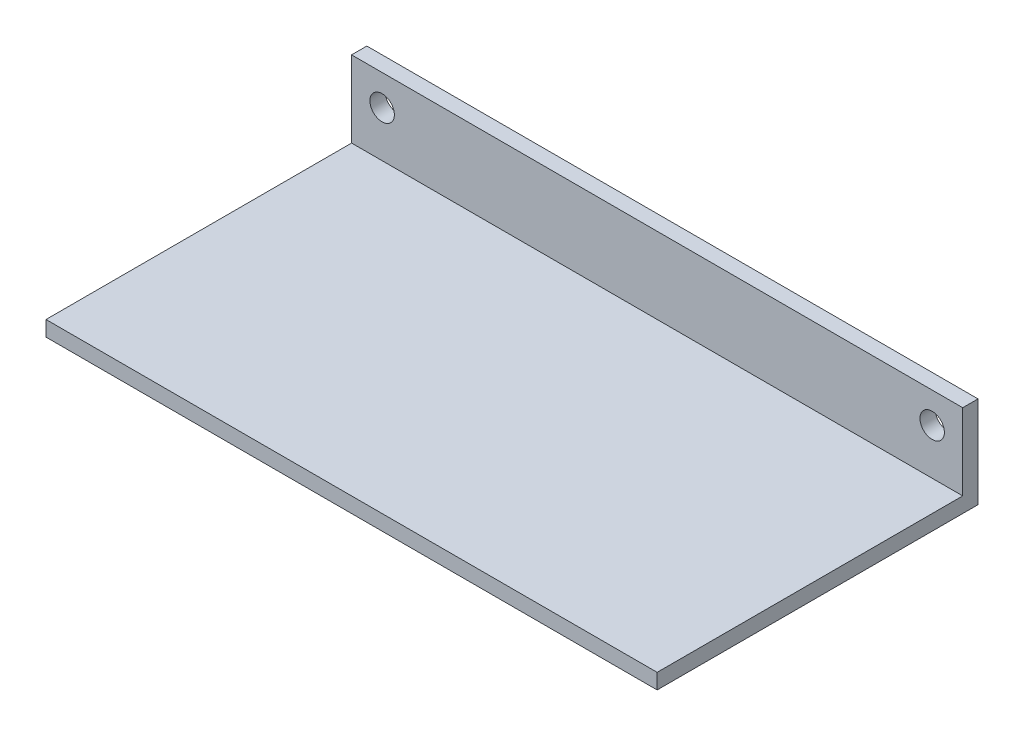
from build123d import *

# Parameters (mm, degrees)
SKETCH1_W           = 200
SKETCH1_H           = 100
BOSS_EXTRUDE1_DEPTH = 5
SKETCH2_W           = 200
SKETCH2_H           = 5
BOSS_EXTRUDE2_DEPTH = 30
SKETCH3_R           = 4
CUT_EXTRUDE1_DEPTH  = 40


with BuildPart() as part:
    # Sketch1 → Boss-Extrude1 (new body)
    with BuildSketch(Plane(origin=(0, 0, 0), x_dir=(1, 0, 0), z_dir=(0, 1, 0))):
        Rectangle(SKETCH1_W, SKETCH1_H)
    extrude(amount=BOSS_EXTRUDE1_DEPTH)

    # Sketch2 → Boss-Extrude2 (add)
    with BuildSketch(Plane.XZ):
        with Locations((0, -52.5)):
            Rectangle(SKETCH2_W, SKETCH2_H)
    extrude(amount=-BOSS_EXTRUDE2_DEPTH)

    # Sketch3 → Cut-Extrude1 (cut)
    with BuildSketch(Plane.XY.offset(-50)):
        with Locations((-90, 20)):
            Circle(SKETCH3_R)
        with Locations((90, 20)):
            Circle(SKETCH3_R)
    extrude(amount=-CUT_EXTRUDE1_DEPTH, mode=Mode.SUBTRACT)


solid = part.part
